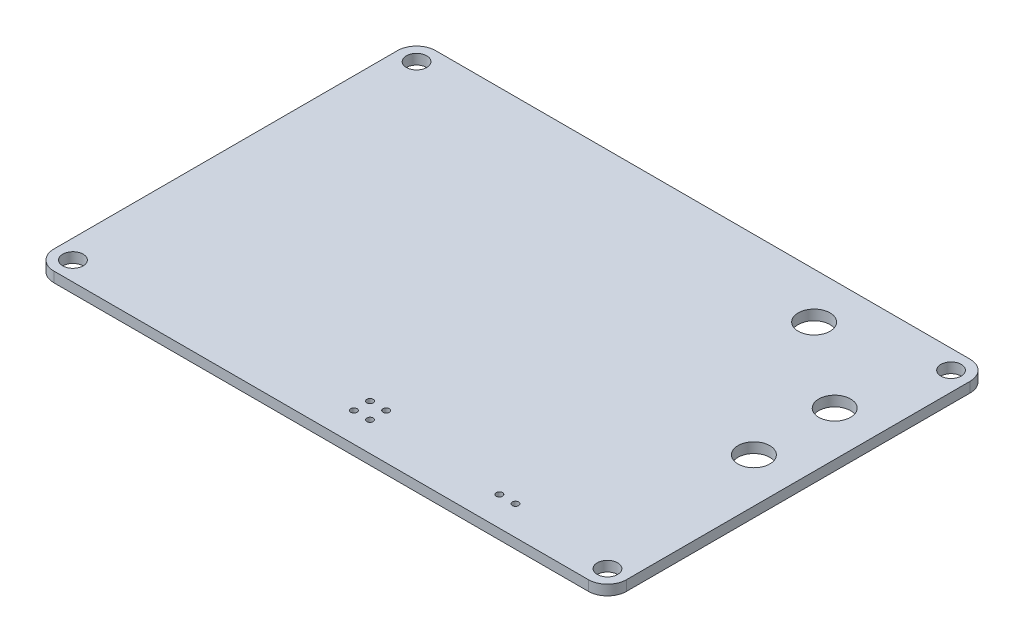
from build123d import *

# Parameters (mm, degrees)
SKETCH1_W           = 90
SKETCH1_H           = 60
BOSS_EXTRUDE1_DEPTH = 1.6
SKETCH2_R           = 1.6
CUT_EXTRUDE1_DEPTH  = 1.6
FILLET1_R           = 3
SKETCH3_R           = 0.5
SKETCH3_R_2         = 2.5
CUT_EXTRUDE2_DEPTH  = 1.6


with BuildPart() as part:
    # Sketch1 → Boss-Extrude1 (new body)
    with BuildSketch(Plane(origin=(0, 0, 0), x_dir=(1, 0, 0), z_dir=(0, 1, 0))):
        Rectangle(SKETCH1_W, SKETCH1_H)
    extrude(amount=BOSS_EXTRUDE1_DEPTH)

    # Sketch2 → Cut-Extrude1 (cut)
    with BuildSketch(Plane(origin=(0, 1.6, 0), x_dir=(-1, 0, 0), z_dir=(0, 1, 0))):
        with Locations((42, -27)):
            Circle(SKETCH2_R)
        with Locations((42, 27)):
            Circle(SKETCH2_R)
        with Locations((-42, 27)):
            Circle(SKETCH2_R)
        with Locations((-42, -27)):
            Circle(SKETCH2_R)
    extrude(amount=-CUT_EXTRUDE1_DEPTH, mode=Mode.SUBTRACT)

    # Fillet1
    fillet1_edges = [part.edges().sort_by_distance(p)[0] for p in [
        (-45, 0.8, -30),
        (45, 0.8, -30),
        (45, 0.8, 30),
        (-45, 0.8, 30),
    ]]
    fillet(fillet1_edges, radius=FILLET1_R)

    # Sketch3 → Cut-Extrude2 (cut)
    with BuildSketch(Plane(origin=(0, 1.6, 0), x_dir=(-1, 0, 0), z_dir=(0, 1, 0))):
        with Locations((-0.55, 25.4)):
            Circle(SKETCH3_R)
        with Locations((-0.55, 22.86)):
            Circle(SKETCH3_R)
        with Locations((-3.09, 25.4)):
            Circle(SKETCH3_R)
        with Locations((-3.09, 22.86)):
            Circle(SKETCH3_R)
        with Locations((-23.41, 25.4)):
            Circle(SKETCH3_R)
        with Locations((-25.95, 25.4)):
            Circle(SKETCH3_R)
        with Locations((-38.015, 0)):
            Circle(SKETCH3_R_2)
        with Locations((-38.015, -12.7)):
            Circle(SKETCH3_R_2)
        with Locations((-24.68, -22.8)):
            Circle(SKETCH3_R_2)
    extrude(amount=-CUT_EXTRUDE2_DEPTH, mode=Mode.SUBTRACT)


solid = part.part
